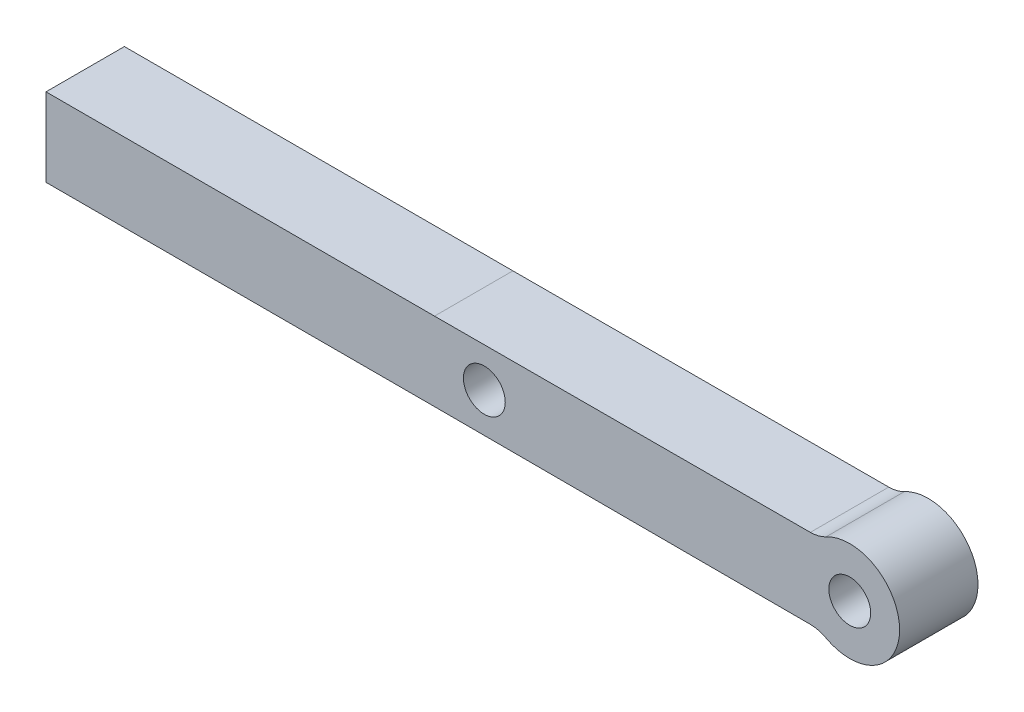
from build123d import *

# Parameters (mm, degrees)
SKETCH1_R           = 1.6
BOSS_EXTRUDE1_DEPTH = 5.9944


with BuildPart() as part:
    # Sketch1 → Boss-Extrude1 (new body)
    with BuildSketch(Plane.XY):
        with BuildLine():
            Line((-3.01403503, 3.046744767), (-31.75, 2.9972))
            Line((-31.75, 2.9972), (-37.7444, 2.9972))
            Line((-37.7444, 2.9972), (-42.403721744, 2.9972))
            Line((-42.403721744, 2.9972), (-61.453721744, 2.9972))
            Line((-61.453721744, 2.9972), (-61.453721744, -2.9972))
            Line((-61.453721744, -2.9972), (-55.103721744, -2.9972))
            Line((-55.103721744, -2.9972), (-42.403721744, -2.9972))
            Line((-42.403721744, -2.9972), (-37.7444, -2.9972))
            Line((-37.7444, -2.9972), (-31.75, -2.9972))
            Line((-31.75, -2.9972), (-3.01403503, -3.046744767))
            ThreePointArc((-3.01403503, -3.046744767), (-2.393607559, -3.124787196), (-1.8110486, -3.352044595))
            ThreePointArc((-1.8110486, -3.352044595), (3.81, 0), (-1.8110486, 3.352044595))
            ThreePointArc((-1.8110486, 3.352044595), (-2.393607559, 3.124787196), (-3.01403503, 3.046744767))
        make_face()
        with Locations((-27.94, 0)):
            Circle(SKETCH1_R, mode=Mode.SUBTRACT)
        Circle(SKETCH1_R, mode=Mode.SUBTRACT)
    extrude(amount=BOSS_EXTRUDE1_DEPTH)


solid = part.part
